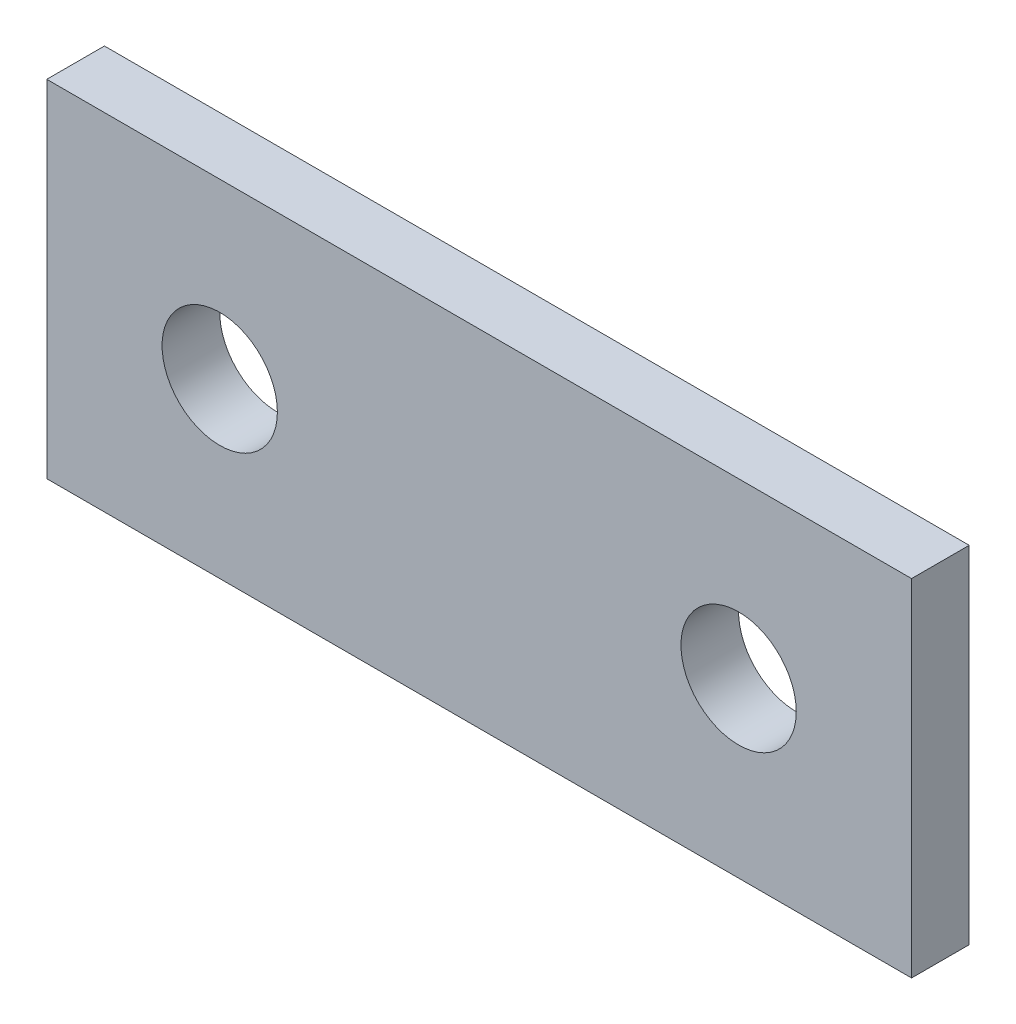
from build123d import *

# Parameters (mm, degrees)
SKETCH1_W           = 15
SKETCH1_H           = 6
SKETCH1_R           = 1
BOSS_EXTRUDE1_DEPTH = 1


with BuildPart() as part:
    # Sketch1 → Boss-Extrude1 (new body)
    with BuildSketch(Plane.XY):
        Rectangle(SKETCH1_W, SKETCH1_H)
        with Locations((4.5, 0)):
            Circle(SKETCH1_R, mode=Mode.SUBTRACT)
        with Locations((-4.5, 0)):
            Circle(SKETCH1_R, mode=Mode.SUBTRACT)
    extrude(amount=BOSS_EXTRUDE1_DEPTH)


solid = part.part
